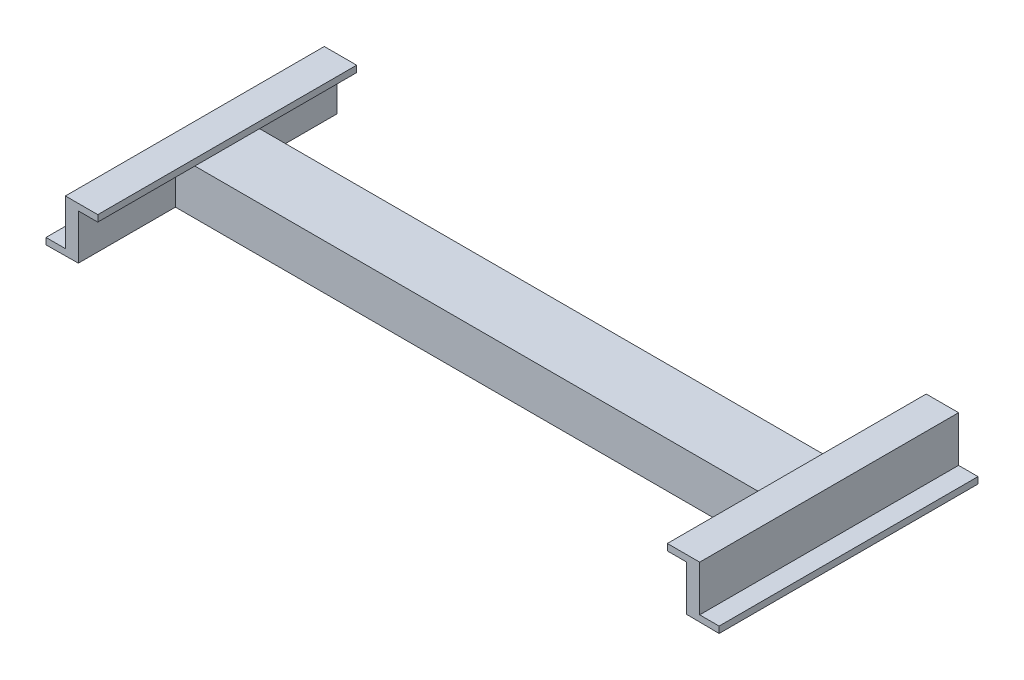
from build123d import *

# Parameters (mm, degrees)
BOSS_EXTRUDE1_DEPTH = 400
BOSS_EXTRUDE2_DEPTH = 470


with BuildPart() as part:
    # Sketch1 → Boss-Extrude1 (new body)
    with BuildSketch(Plane.XY):
        Polygon((10.586659127, 38.043305377), (10.586659127, -32.473936002), (40.586659127, -32.473936002), (40.586659127, -42.473936002), (-9.413340873, -41.956694623), (-9.413340873, 28.043305377), (-39.413340873, 28.043305377), (-39.413340873, 38.043305377), align=None)
    boss_extrude1 = extrude(amount=BOSS_EXTRUDE1_DEPTH)

    # Sketch2 → Boss-Extrude2 (add)
    with BuildSketch(Plane.ZY.offset(9.413340873)):
        Polygon((150, 28.043305377), (250, 28.043305377), (250, -41.956694623), (240, -41.956694623), (240, 18.043305377), (160, 18.043305377), (160, -41.956694623), (150, -41.956694623), align=None)
    boss_extrude2 = extrude(amount=BOSS_EXTRUDE2_DEPTH)

    # Mirror2: Boss-Extrude2 across plane
    add(boss_extrude2.mirror(Plane.ZY.offset(479.413340873)))

    # Mirror3: Boss-Extrude1 across plane
    add(boss_extrude1.mirror(Plane.ZY.offset(479.413340873)))


solid = part.part
